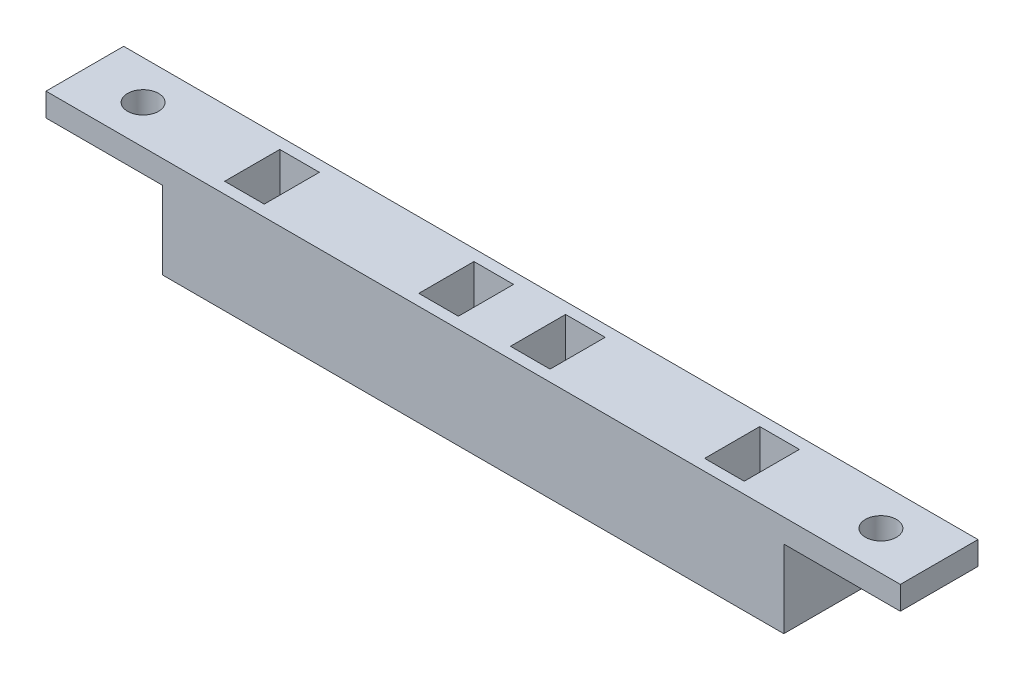
from build123d import *

# Parameters (mm, degrees)
SKETCH1_W           = 80
SKETCH1_H           = 10
BOSS_EXTRUDE1_DEPTH = 10
SKETCH2_W           = 4.7
SKETCH2_H           = 6.7
CUT_EXTRUDE1_DEPTH  = 7
SKETCH3_W           = 4.7
SKETCH3_H           = 6.7
SKETCH4_W           = 7.3
SKETCH4_H           = 7.3
SKETCH5_W           = 4.7
SKETCH5_H           = 6.7
SKETCH6_W           = 7.3
SKETCH6_H           = 7.3
SKETCH8_W           = 4.7
SKETCH8_H           = 6.7
SKETCH9_W           = 7.3
SKETCH9_H           = 7.3
SKETCH10_W          = 4.7
SKETCH10_H          = 6.7
SKETCH11_W          = 7.3
SKETCH11_H          = 7.3
SKETCH12_W          = 110
SKETCH12_H          = 10
SKETCH12_W_2        = 4.7
SKETCH12_H_2        = 6.7
BOSS_EXTRUDE2_DEPTH = 3
SKETCH13_W          = 5.1
SKETCH13_H          = 7.1
CUT_EXTRUDE2_DEPTH  = 5.5
SKETCH14_R          = 2
CUT_EXTRUDE3_DEPTH  = 10


with BuildPart() as part:
    # Sketch1 → Boss-Extrude1 (new body)
    with BuildSketch(Plane(origin=(0, 0, 0), x_dir=(1, 0, 0), z_dir=(0, 1, 0))):
        with Locations((-32.862980486, 9.613188287)):
            Rectangle(SKETCH1_W, SKETCH1_H)
    extrude(amount=BOSS_EXTRUDE1_DEPTH)

    # Sketch2 → Cut-Extrude1 (cut)
    with BuildSketch(Plane(origin=(0, 10, 0), x_dir=(1, 0, 0), z_dir=(0, 1, 0))):
        with Locations((-26.962980486, 9.613188287)):
            Rectangle(SKETCH2_W, SKETCH2_H)
        with Locations((-38.762980486, 9.613188287)):
            Rectangle(SKETCH2_W, SKETCH2_H)
        with Locations((-1.962980486, 9.613188287)):
            Rectangle(SKETCH2_W, SKETCH2_H)
        with Locations((-63.762980486, 9.613188287)):
            Rectangle(SKETCH2_W, SKETCH2_H)
    extrude(amount=-CUT_EXTRUDE1_DEPTH, mode=Mode.SUBTRACT)

    # Sketch3 → Cut-Loft1 section 0
    with BuildSketch(Plane(origin=(0, 3, 0), x_dir=(1, 0, 0), z_dir=(0, 1, 0))):
        with Locations((-38.762980486, 9.613188287)):
            Rectangle(SKETCH3_W, SKETCH3_H)
    # Sketch4 → Cut-Loft1 section 1
    with BuildSketch(Plane.XZ):
        with Locations((-38.762980486, -9.613188287)):
            Rectangle(SKETCH4_W, SKETCH4_H)
    loft(mode=Mode.SUBTRACT)

    # Sketch5 → Cut-Loft2 section 0
    with BuildSketch(Plane(origin=(0, 3, 0), x_dir=(1, 0, 0), z_dir=(0, 1, 0))):
        with Locations((-63.762980486, 9.613188287)):
            Rectangle(SKETCH5_W, SKETCH5_H)
    # Sketch6 → Cut-Loft2 section 1
    with BuildSketch(Plane.XZ):
        with Locations((-63.762980486, -9.613188287)):
            Rectangle(SKETCH6_W, SKETCH6_H)
    loft(mode=Mode.SUBTRACT)

    # Sketch8 → Cut-Loft3 section 0
    with BuildSketch(Plane(origin=(0, 3, 0), x_dir=(1, 0, 0), z_dir=(0, 1, 0))):
        with Locations((-26.962980486, 9.613188287)):
            Rectangle(SKETCH8_W, SKETCH8_H)
    # Sketch9 → Cut-Loft3 section 1
    with BuildSketch(Plane.XZ):
        with Locations((-26.962980486, -9.613188287)):
            Rectangle(SKETCH9_W, SKETCH9_H)
    loft(mode=Mode.SUBTRACT)

    # Sketch10 → Cut-Loft4 section 0
    with BuildSketch(Plane(origin=(0, 3, 0), x_dir=(1, 0, 0), z_dir=(0, 1, 0))):
        with Locations((-1.962980486, 9.613188287)):
            Rectangle(SKETCH10_W, SKETCH10_H)
    # Sketch11 → Cut-Loft4 section 1
    with BuildSketch(Plane.XZ):
        with Locations((-1.962980486, -9.613188287)):
            Rectangle(SKETCH11_W, SKETCH11_H)
    loft(mode=Mode.SUBTRACT)

    # Sketch12 → Boss-Extrude2 (add)
    with BuildSketch(Plane(origin=(0, 10, 0), x_dir=(1, 0, 0), z_dir=(0, 1, 0))):
        with Locations((-32.862980486, 9.613188287)):
            Rectangle(SKETCH12_W, SKETCH12_H)
        with Locations((-63.762980486, 9.613188287)):
            Rectangle(SKETCH12_W_2, SKETCH12_H_2, mode=Mode.SUBTRACT)
        with Locations((-38.762980486, 9.613188287)):
            Rectangle(SKETCH12_W_2, SKETCH12_H_2, mode=Mode.SUBTRACT)
        with Locations((-26.962980486, 9.613188287)):
            Rectangle(SKETCH12_W_2, SKETCH12_H_2, mode=Mode.SUBTRACT)
        with Locations((-1.962980486, 9.613188287)):
            Rectangle(SKETCH12_W_2, SKETCH12_H_2, mode=Mode.SUBTRACT)
    extrude(amount=BOSS_EXTRUDE2_DEPTH)

    # Sketch13 → Cut-Extrude2 (cut)
    with BuildSketch(Plane(origin=(0, 13, 0), x_dir=(1, 0, 0), z_dir=(0, 1, 0))):
        with Locations((-63.762980486, 9.613188287)):
            Rectangle(SKETCH13_W, SKETCH13_H)
        with Locations((-38.762980486, 9.613188287)):
            Rectangle(SKETCH13_W, SKETCH13_H)
        with Locations((-26.962980486, 9.613188287)):
            Rectangle(SKETCH13_W, SKETCH13_H)
        with Locations((-1.962980486, 9.613188287)):
            Rectangle(SKETCH13_W, SKETCH13_H)
    extrude(amount=-CUT_EXTRUDE2_DEPTH, mode=Mode.SUBTRACT)

    # Sketch14 → Cut-Extrude3 (cut)
    with BuildSketch(Plane(origin=(0, 13, 0), x_dir=(1, 0, 0), z_dir=(0, 1, 0))):
        with Locations((14.637019514, 9.613188287)):
            Circle(SKETCH14_R)
        with Locations((-80.362980486, 9.613188287)):
            Circle(SKETCH14_R)
    extrude(amount=-CUT_EXTRUDE3_DEPTH, mode=Mode.SUBTRACT)


solid = part.part
